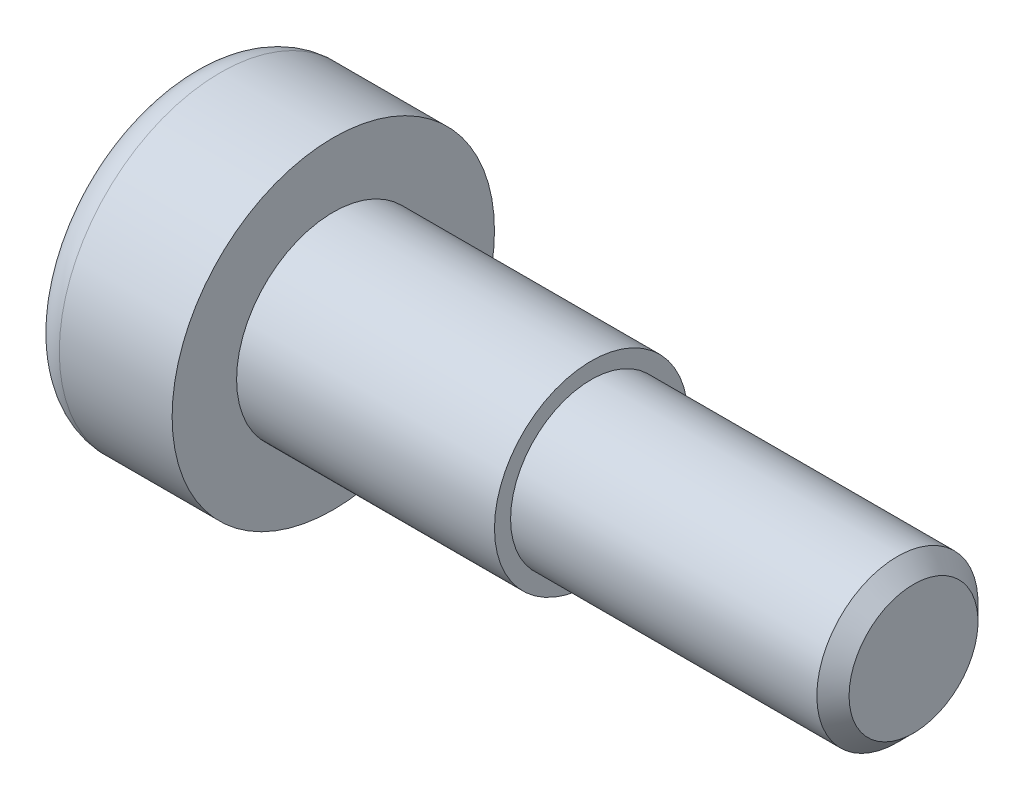
from build123d import *

# Parameters (mm, degrees)
CUT_EXTRUDE_1_DEPTH = 3
FILLET_1_R          = 1
CHAMFER_1_SIZE      = 0.5


with BuildPart() as part:
    # 草图1 → 旋转1 (revolve)
    with BuildSketch(Plane.XY):
        Polygon((0, 0), (0, 5), (4.5, 5), (4.5, 3), (12.5, 3), (12.5, 2.5), (22.5, 2.5), (22.5, 0), align=None)
    revolve(axis=Axis((0, 0, 0), (1, 0, 0)))

    # 草图2 → 切除-拉伸1 (cut)
    with BuildSketch(Plane.ZY):
        Polygon((0, 1.732050808), (-1.5, 0.866025404), (-1.5, -0.866025404), (0, -1.732050808), (1.5, -0.866025404), (1.5, 0.866025404), align=None)
    extrude(amount=-CUT_EXTRUDE_1_DEPTH, mode=Mode.SUBTRACT)

    # 圆角1
    fillet_1_edges = [part.edges().sort_by_distance(p)[0] for p in [
        (0, -5, 0),
    ]]
    fillet(fillet_1_edges, radius=FILLET_1_R)

    # 倒角1
    chamfer_1_edges = [part.edges().sort_by_distance(p)[0] for p in [
        (22.5, -2.5, 0),
    ]]
    chamfer(chamfer_1_edges, length=CHAMFER_1_SIZE)


solid = part.part
